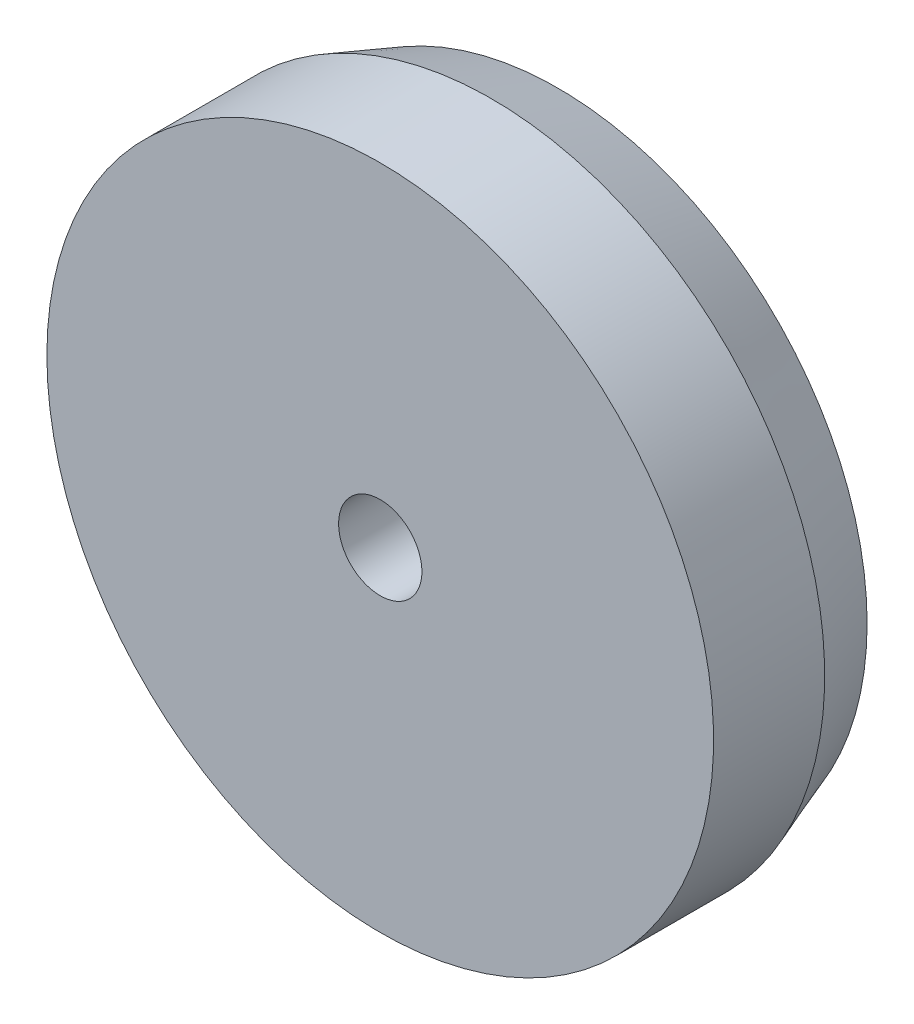
from build123d import *


with BuildPart() as part:
    # Sketch1 → Revolve1 (revolve)
    with BuildSketch(Plane.XZ.offset(10.646000252)):
        with BuildLine():
            Line((5.297017702, -1.87), (5.297017702, -1.67))
            Line((5.297017702, -1.67), (4.772017702, -1.67))
            Line((4.772017702, -1.67), (4.772017702, -1.87))
            ThreePointArc((4.772017702, -1.87), (4.966287548, -1.908844231), (5.147017702, -1.99))
            Line((5.147017702, -1.99), (5.253341274, -1.99))
            Line((5.253341274, -1.99), (5.297017702, -1.87))
        make_face()
    revolve(axis=Axis((4.697017702, -10.646000252, -1.67), (0, 0, -1)))


solid = part.part
